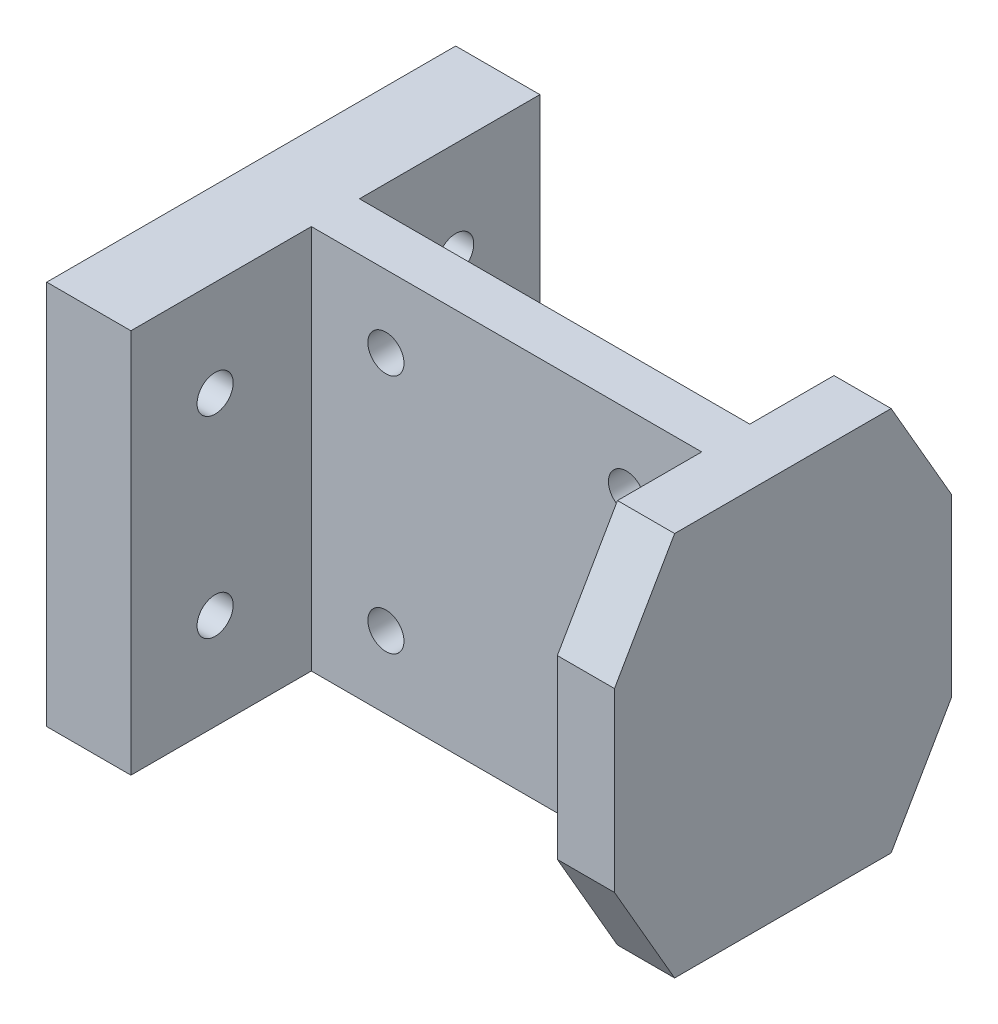
from build123d import *

# Parameters (mm, degrees)
SKETCH_1_W          = 36
SKETCH_1_H          = 32
SKETCH_1_R          = 1.5
EXTRUDE_1_DEPTH     = 4
EXTRUDE_2_DEPTH     = 32
SKETCH_8_R          = 1.5
CUT_EXTRUDE_1_DEPTH = 5
SKETCH1_W           = 4
SKETCH1_H           = 32
BOSS_EXTRUDE1_DEPTH = 3
SKETCH2_W           = 5
SKETCH2_H           = 32
BOSS_EXTRUDE2_DEPTH = 12
CUT_EXTRUDE1_DEPTH  = 5
BOSS_EXTRUDE5_DEPTH = 5
SKETCH7_W           = 15
SKETCH7_H           = 32
SKETCH7_R           = 1.5
BOSS_EXTRUDE6_DEPTH = 3
CUT_EXTRUDE2_DEPTH  = 0.25


with BuildPart() as part:
    # Эскиз1 → Бобышка-Вытянуть1 (new body)
    with BuildSketch(Plane.XY):
        with Locations((18, 16)):
            Rectangle(SKETCH_1_W, SKETCH_1_H)
        with Locations((8, 26)):
            Circle(SKETCH_1_R, mode=Mode.SUBTRACT)
        with Locations((28, 26)):
            Circle(SKETCH_1_R, mode=Mode.SUBTRACT)
        with Locations((8, 6)):
            Circle(SKETCH_1_R, mode=Mode.SUBTRACT)
        with Locations((28, 6)):
            Circle(SKETCH_1_R, mode=Mode.SUBTRACT)
    extrude(amount=EXTRUDE_1_DEPTH)

    # Эскиз7 → Бобышка-Вытянуть2 (add)
    with BuildSketch(Plane(origin=(0, 32, 0), x_dir=(1, 0, 0), z_dir=(0, 1, 0))):
        Polygon((0, 0), (-1.2, 0), (-1.2, 15), (-5.2, 15), (-5.2, -19), (-1.2, -19), (-1.2, -4), (0, -4), align=None)
    extrude(amount=-EXTRUDE_2_DEPTH)

    # Эскиз8 → Вырез-Вытянуть1 (cut, through all)
    with BuildSketch(Plane(origin=(-1.2, 0, 0), x_dir=(0, 0, -1), z_dir=(1, 0, 0))):
        with Locations((8, 24)):
            Circle(SKETCH_8_R)
        with Locations((8, 8)):
            Circle(SKETCH_8_R)
        with Locations((-12, 8)):
            Circle(SKETCH_8_R)
        with Locations((-12, 24)):
            Circle(SKETCH_8_R)
    extrude(amount=-CUT_EXTRUDE_1_DEPTH, mode=Mode.SUBTRACT)

    # Sketch1 → Boss-Extrude1 (add)
    with BuildSketch(Plane(origin=(36, 0, 0), x_dir=(0, 0, -1), z_dir=(1, 0, 0))):
        with Locations((-2, 16)):
            Rectangle(SKETCH1_W, SKETCH1_H)
    extrude(amount=BOSS_EXTRUDE1_DEPTH)

    # Sketch2 → Boss-Extrude2 (add)
    with BuildSketch(Plane(origin=(0, 0, 0), x_dir=(-1, 0, 0), z_dir=(0, 0, -1))):
        with Locations((-36.5, 16)):
            Rectangle(SKETCH2_W, SKETCH2_H)
    extrude(amount=BOSS_EXTRUDE2_DEPTH)

    # Sketch3 → Cut-Extrude1 (cut)
    with BuildSketch(Plane(origin=(39, 0, 0), x_dir=(0, 0, -1), z_dir=(1, 0, 0))):
        Polygon((7, 32), (12, 32), (12, 23.339745962), align=None)
        Polygon((12, 8.660254038), (7, 0), (12, 0), align=None)
    extrude(amount=-CUT_EXTRUDE1_DEPTH, mode=Mode.SUBTRACT)

    # Sketch6 → Boss-Extrude5 (add)
    with BuildSketch(Plane(origin=(39, 0, 0), x_dir=(0, 0, -1), z_dir=(1, 0, 0))):
        Polygon((-16, 8.660254038), (-11, 0), (-4, 0), (-4, 32), (-11, 32), (-16, 23.339745962), align=None)
    extrude(amount=-BOSS_EXTRUDE5_DEPTH)

    # Sketch7 → Boss-Extrude6 (add)
    with BuildSketch(Plane(origin=(-1.2, 0, 0), x_dir=(0, 0, -1), z_dir=(1, 0, 0))):
        with Locations((7.5, 16)):
            Rectangle(SKETCH7_W, SKETCH7_H)
        with Locations((8, 24)):
            Circle(SKETCH7_R, mode=Mode.SUBTRACT)
        with Locations((8, 8)):
            Circle(SKETCH7_R, mode=Mode.SUBTRACT)
        with Locations((-11.5, 16)):
            Rectangle(SKETCH7_W, SKETCH7_H)
        with Locations((-12, 24)):
            Circle(SKETCH7_R, mode=Mode.SUBTRACT)
        with Locations((-12, 8)):
            Circle(SKETCH7_R, mode=Mode.SUBTRACT)
    extrude(amount=BOSS_EXTRUDE6_DEPTH)

    # Sketch8 → Cut-Extrude2 (cut)
    with BuildSketch(Plane.ZY.offset(-34)):
        Polygon((-12, 23.339745962), (-12, 8.660254038), (-7, 0), (0, 0), (0, 32), (-7, 32), align=None)
        Polygon((4, 32), (4, 0), (11, 0), (16, 8.660254038), (16, 23.339745962), (11, 32), align=None)
    extrude(amount=-CUT_EXTRUDE2_DEPTH, mode=Mode.SUBTRACT)


solid = part.part
